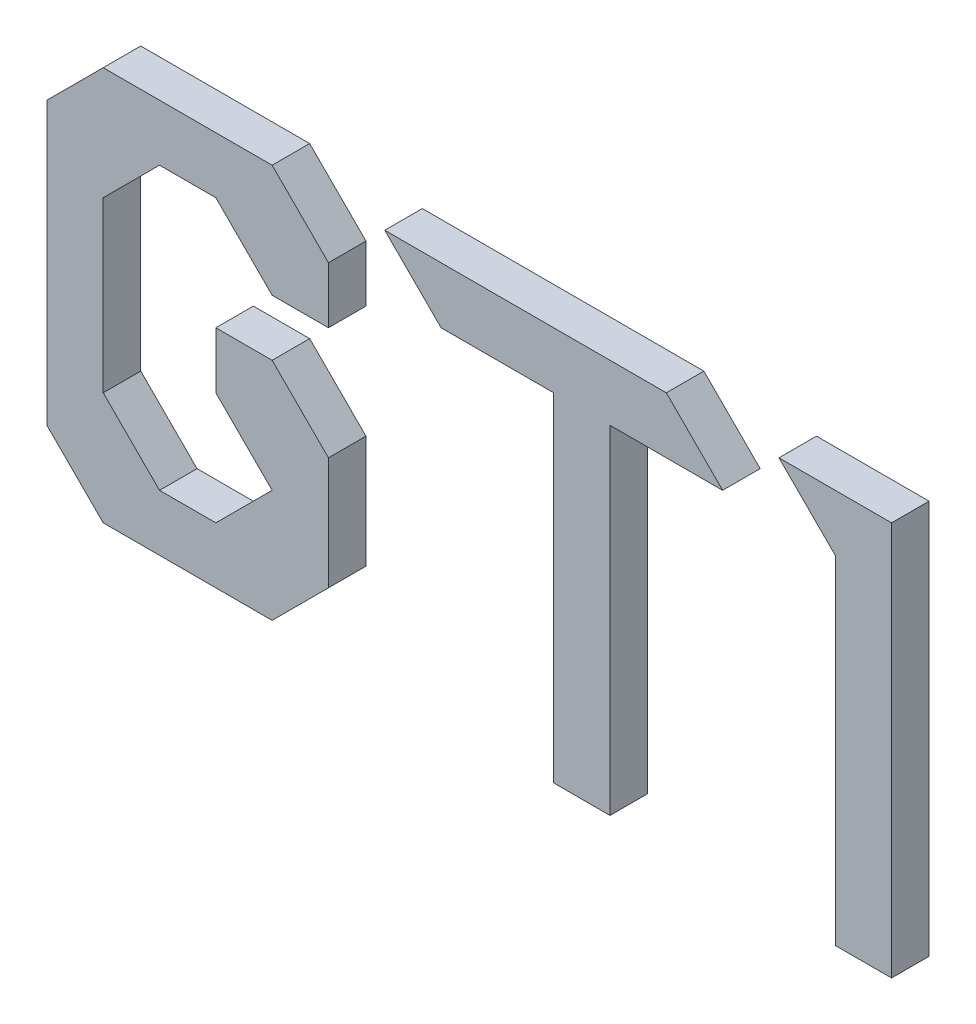
from build123d import *

# Parameters (mm, degrees)
SKETCH2_W      = 15
SKETCH2_H      = 90
EXTRUDE1_DEPTH = 10


with BuildPart() as part:
    # Sketch2 → Extrude1 (new body)
    with BuildSketch(Plane.XY):
        Polygon((75, 15), (60, 0), (15, 0), (0, 15), (0, 90), (15, 105), (60, 105), (75, 90), (75, 75), (60, 75), (45, 90), (30, 90), (15, 75), (15, 30), (30, 15), (45, 15), (60, 30), (45, 45), (45, 60), (60, 60), (75, 45), align=None)
        Polygon((180, 90), (165, 90), (135, 90), (120, 90), (105, 90), (90, 105), (150, 105), (165, 105), align=None)
        Polygon((225, 0), (225, 105), (195, 105), (210, 90), (210, 0), align=None)
        with Locations((142.5, 45)):
            Rectangle(SKETCH2_W, SKETCH2_H)
    extrude(amount=EXTRUDE1_DEPTH)


solid = part.part
